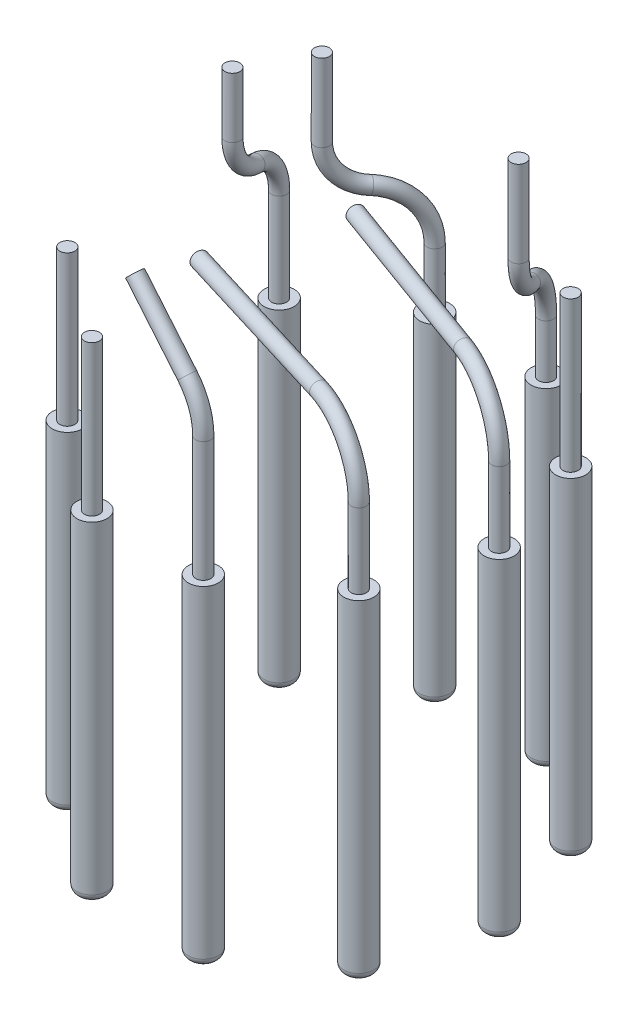
from build123d import *

# Parameters (mm, degrees)
EXTRUDE2_DEPTH        = 4.5
EXTRUDE2_DEPTH_BACK   = 6.5
SKETCH1_R             = 0.5
EXTRUDE2_2_DEPTH      = 4.5
EXTRUDE2_2_DEPTH_BACK = 6.5
EXTRUDE2_3_DEPTH      = 4.5
EXTRUDE2_3_DEPTH_BACK = 6.5
EXTRUDE2_4_DEPTH      = 4.5
EXTRUDE2_4_DEPTH_BACK = 6.5
EXTRUDE2_5_DEPTH      = 4.5
EXTRUDE2_5_DEPTH_BACK = 6.5
EXTRUDE2_6_DEPTH      = 4.5
EXTRUDE2_6_DEPTH_BACK = 6.5
EXTRUDE2_7_DEPTH      = 4.5
EXTRUDE2_7_DEPTH_BACK = 6.5
EXTRUDE2_8_DEPTH      = 4.5
EXTRUDE2_8_DEPTH_BACK = 6.5
EXTRUDE2_9_DEPTH      = 4.5
EXTRUDE2_9_DEPTH_BACK = 6.5
SKETCH3_R             = 0.25
EXTRUDE3_DEPTH        = 5
FILLET1_R             = 0.25
FILLET2_R             = 0.25
FILLET3_R             = 0.25
FILLET4_R             = 0.25
FILLET5_R             = 0.25
FILLET6_R             = 0.25
FILLET7_R             = 0.25
FILLET8_R             = 0.25
FILLET9_R             = 0.25
SKETCH5_R             = 0.25
SKETCH7_R             = 0.25
SKETCH9_R             = 0.25
SKETCH12_R            = 0.25
SKETCH14_R            = 0.25
SKETCH16_R            = 0.25


with BuildPart() as part:
    # Sketch1 → Extrude2 (new, two sides: drawn at the far end of the back side and taken through both)
    with BuildSketch(Plane(origin=(0, 0, 0), x_dir=(1, 0, 0), z_dir=(0, 1, 0)).offset(-EXTRUDE2_DEPTH_BACK)):
        with Locations((6, 0)):
            Circle(SKETCH1_R)
    extrude(amount=EXTRUDE2_DEPTH + EXTRUDE2_DEPTH_BACK)

    # Fillet9
    fillet9_edges = [part.edges().sort_by_distance(p)[0] for p in [
        (5.5, -6.5, 0),
    ]]
    fillet(fillet9_edges, radius=FILLET9_R)

    # Sweep3: sweep along a path in Sketch8
    with BuildLine(Plane(origin=(0.701866671, 0, -1.928362829), x_dir=(0.9396926207859082, 0, 0.3420201433256695), z_dir=(-0.3420201433256695, 0, 0.9396926207859082))) as sweep3_path:
        Line((5.638155725, 4.5), (5.638155725, 7))
        ThreePointArc((5.638155725, 7), (5.052369287, 8.414213562), (3.638155725, 9))
        Line((3.638155725, 9), (-2.361844275, 9))
    # Sketch9 → Sweep3 (sweep)
    with BuildSketch(Plane(origin=(0, 4.5, 0), x_dir=(-1, 0, 0), z_dir=(0, 1, 0))):
        with Locations((-6, 0)):
            Circle(SKETCH9_R)
    sweep(path=sweep3_path.line)


with BuildPart() as body_2:
    # Sketch1 → Extrude2 2 (new, two sides: drawn at the far end of the back side and taken through both)
    with BuildSketch(Plane(origin=(0, 0, 0), x_dir=(1, 0, 0), z_dir=(0, 1, 0)).offset(-EXTRUDE2_2_DEPTH_BACK)):
        with Locations((4.854101966, -3.526711514)):
            Circle(SKETCH1_R)
    extrude(amount=EXTRUDE2_2_DEPTH + EXTRUDE2_2_DEPTH_BACK)

    # Fillet8
    fillet8_edges = [body_2.edges().sort_by_distance(p)[0] for p in [
        (4.354101966, -6.5, 3.526711514),
    ]]
    fillet(fillet8_edges, radius=FILLET8_R)

    # Sweep2: sweep along a path in Sketch6
    with BuildLine(Plane(origin=(-0.571121498, 0, 1.868054247), x_dir=(0.9563047559630353, 0, 0.2923717047227373), z_dir=(-0.2923717047227373, 0, 0.9563047559630353))) as sweep2_path:
        Line((5.673111454, 4.5), (5.673111454, 7))
        ThreePointArc((5.673111454, 7), (5.087325016, 8.414213562), (3.673111454, 9))
        Line((3.673111454, 9), (-2.326888546, 9))
    # Sketch7 → Sweep2 (sweep)
    with BuildSketch(Plane(origin=(0, 4.5, 0), x_dir=(-1, 0, 0), z_dir=(0, 1, 0))):
        with Locations((-4.854101966, 3.526711514)):
            Circle(SKETCH7_R)
    sweep(path=sweep2_path.line)


with BuildPart() as body_3:
    # Sketch1 → Extrude2 3 (new, two sides: drawn at the far end of the back side and taken through both)
    with BuildSketch(Plane(origin=(0, 0, 0), x_dir=(1, 0, 0), z_dir=(0, 1, 0)).offset(-EXTRUDE2_3_DEPTH_BACK)):
        with Locations((1.854101966, -5.706339098)):
            Circle(SKETCH1_R)
    extrude(amount=EXTRUDE2_3_DEPTH + EXTRUDE2_3_DEPTH_BACK)

    # Fillet7
    fillet7_edges = [body_3.edges().sort_by_distance(p)[0] for p in [
        (1.354101966, -6.5, 5.706339098),
    ]]
    fillet(fillet7_edges, radius=FILLET7_R)

    # Sweep1: sweep along a path in Sketch4
    with BuildLine(Plane(origin=(-0.481363705, 0, 5.502012327), x_dir=(0.9961946980917457, 0, 0.08715574274765837), z_dir=(-0.08715574274765837, 0, 0.9961946980917457))) as sweep1_path:
        Line((2.344386771, 4.5), (2.344386771, 8.5))
        ThreePointArc((2.344386771, 8.5), (2.192145836, 9.265366865), (1.758600333, 9.914213562))
        Line((1.758600333, 9.914213562), (-0.155613229, 11.828427125))
    # Sketch5 → Sweep1 (sweep)
    with BuildSketch(Plane(origin=(0, 4.5, 0), x_dir=(-1, 0, 0), z_dir=(0, 1, 0))):
        with Locations((-1.854101966, 5.706339098)):
            Circle(SKETCH5_R)
    sweep(path=sweep1_path.line)


with BuildPart() as body_4:
    # Sketch1 → Extrude2 4 (new, two sides: drawn at the far end of the back side and taken through both)
    with BuildSketch(Plane(origin=(0, 0, 0), x_dir=(1, 0, 0), z_dir=(0, 1, 0)).offset(-EXTRUDE2_4_DEPTH_BACK)):
        with Locations((-1.854101966, -5.706339098)):
            Circle(SKETCH1_R)
    extrude(amount=EXTRUDE2_4_DEPTH + EXTRUDE2_4_DEPTH_BACK)



with BuildPart() as body_5:
    # Sketch1 → Extrude2 5 (new, two sides: drawn at the far end of the back side and taken through both)
    with BuildSketch(Plane(origin=(0, 0, 0), x_dir=(1, 0, 0), z_dir=(0, 1, 0)).offset(-EXTRUDE2_5_DEPTH_BACK)):
        with Locations((-4.854101966, -3.526711514)):
            Circle(SKETCH1_R)
    extrude(amount=EXTRUDE2_5_DEPTH + EXTRUDE2_5_DEPTH_BACK)


with BuildPart() as body_6:
    # Sketch1 → Extrude2 6 (new, two sides: drawn at the far end of the back side and taken through both)
    with BuildSketch(Plane(origin=(0, 0, 0), x_dir=(1, 0, 0), z_dir=(0, 1, 0)).offset(-EXTRUDE2_6_DEPTH_BACK)):
        with Locations((-4.854101966, 3.526711514)):
            Circle(SKETCH1_R)
    extrude(amount=EXTRUDE2_6_DEPTH + EXTRUDE2_6_DEPTH_BACK)

    # Fillet4
    fillet4_edges = [body_6.edges().sort_by_distance(p)[0] for p in [
        (-5.354101966, -6.5, -3.526711514),
    ]]
    fillet(fillet4_edges, radius=FILLET4_R)

    # Sweep6: sweep along a path in Sketch15
    with BuildLine(Plane(origin=(-3.647260912, 0, 0.977280616), x_dir=(0.258819045102518, 0, 0.9659258262890691), z_dir=(-0.9659258262890691, 0, 0.258819045102518))) as sweep6_path:
        Line((-4.662875769, 4.5), (-4.662875769, 7.608633541))
        ThreePointArc((-4.662875769, 7.608633541), (-4.356609407, 8.516928647), (-3.562875769, 9.054316771))
        ThreePointArc((-3.562875769, 9.054316771), (-2.76914213, 9.591704894), (-2.462875769, 10.5))
        Line((-2.462875769, 10.5), (-2.462875769, 12.5))
    # Sketch16 → Sweep6 (sweep)
    with BuildSketch(Plane(origin=(0, 4.5, 0), x_dir=(1, 0, 0), z_dir=(0, 1, 0))):
        with Locations((-4.854101966, 3.526711514)):
            Circle(SKETCH16_R)
    sweep(path=sweep6_path.line)


with BuildPart() as body_7:
    # Sketch1 → Extrude2 7 (new, two sides: drawn at the far end of the back side and taken through both)
    with BuildSketch(Plane(origin=(0, 0, 0), x_dir=(1, 0, 0), z_dir=(0, 1, 0)).offset(-EXTRUDE2_7_DEPTH_BACK)):
        with Locations((-1.854101966, 5.706339098)):
            Circle(SKETCH1_R)
    extrude(amount=EXTRUDE2_7_DEPTH + EXTRUDE2_7_DEPTH_BACK)

    # Fillet3
    fillet3_edges = [body_7.edges().sort_by_distance(p)[0] for p in [
        (-2.354101966, -6.5, -5.706339098),
    ]]
    fillet(fillet3_edges, radius=FILLET3_R)

    # Sweep5: sweep along a path in Sketch13
    with BuildLine(Plane(origin=(-3.861493785, 0, -2.229434476), x_dir=(0.5000000000000009, 0, -0.866025403784438), z_dir=(0.8660254037844382, 0, 0.500000000000001))) as sweep5_path:
        Line((4.014783638, 4.5), (4.014783638, 6.5))
        ThreePointArc((4.014783638, 6.5), (3.573171083, 7.753566341), (2.443355067, 8.453542047))
        ThreePointArc((2.443355067, 8.453542047), (1.595993054, 8.978523827), (1.264783638, 9.918698583))
        Line((1.264783638, 9.918698583), (1.264783638, 12.5))
    # Sketch14 → Sweep5 (sweep)
    with BuildSketch(Plane(origin=(0, 4.5, 0), x_dir=(1, 0, 0), z_dir=(0, 1, 0))):
        with Locations((-1.854101966, 5.706339098)):
            Circle(SKETCH14_R)
    sweep(path=sweep5_path.line)


with BuildPart() as body_8:
    # Sketch1 → Extrude2 8 (new, two sides: drawn at the far end of the back side and taken through both)
    with BuildSketch(Plane(origin=(0, 0, 0), x_dir=(1, 0, 0), z_dir=(0, 1, 0)).offset(-EXTRUDE2_8_DEPTH_BACK)):
        with Locations((1.854101966, 5.706339098)):
            Circle(SKETCH1_R)
    extrude(amount=EXTRUDE2_8_DEPTH + EXTRUDE2_8_DEPTH_BACK)

    # Fillet2
    fillet2_edges = [body_8.edges().sort_by_distance(p)[0] for p in [
        (1.354101966, -6.5, -5.706339098),
    ]]
    fillet(fillet2_edges, radius=FILLET2_R)

    # Sweep4: sweep along a path in Sketch10
    with BuildLine(Plane(origin=(3.861493785, 0, -2.229434476), x_dir=(-0.500000000000001, 0, -0.8660254037844382), z_dir=(0.8660254037844382, 0, -0.500000000000001))) as sweep4_path:
        Line((4.014783638, 4.5), (4.014783638, 6.275624505))
        ThreePointArc((4.014783638, 6.275624505), (3.61835109, 7.470853114), (2.58621221, 8.1922542))
        ThreePointArc((2.58621221, 8.1922542), (1.81210805, 8.733305014), (1.514783638, 9.629726471))
        Line((1.514783638, 9.629726471), (1.514783638, 12.5))
    # Sketch12 → Sweep4 (sweep)
    with BuildSketch(Plane(origin=(0, 4.5, 0), x_dir=(1, 0, 0), z_dir=(0, 1, 0))):
        with Locations((1.854101966, 5.706339098)):
            Circle(SKETCH12_R)
    sweep(path=sweep4_path.line)


with BuildPart() as body_9:
    # Sketch1 → Extrude2 9 (new, two sides: drawn at the far end of the back side and taken through both)
    with BuildSketch(Plane(origin=(0, 0, 0), x_dir=(1, 0, 0), z_dir=(0, 1, 0)).offset(-EXTRUDE2_9_DEPTH_BACK)):
        with Locations((4.854101966, 3.526711514)):
            Circle(SKETCH1_R)
    extrude(amount=EXTRUDE2_9_DEPTH + EXTRUDE2_9_DEPTH_BACK)


with BuildPart() as body_4_1:
    add(body_4.part)

    add(body_5.part)  # Extrude3 merges body 5

    add(body_9.part)  # Extrude3 merges body 9
    # Sketch3 → Extrude3 (add)
    with BuildSketch(Plane(origin=(0, 4.5, 0), x_dir=(-1, 0, 0), z_dir=(0, 1, 0))):
        with Locations((4.854101966, 3.526711514)):
            Circle(SKETCH3_R)
        with Locations((1.854101966, 5.706339098)):
            Circle(SKETCH3_R)
        with Locations((-4.854101966, -3.526711514)):
            Circle(SKETCH3_R)
    extrude(amount=EXTRUDE3_DEPTH)

    # Fillet1
    fillet1_edges = [body_4_1.edges().sort_by_distance(p)[0] for p in [
        (4.354101966, -6.5, -3.526711514),
    ]]
    fillet(fillet1_edges, radius=FILLET1_R)

    # Fillet5
    fillet5_edges = [body_4_1.edges().sort_by_distance(p)[0] for p in [
        (-5.354101966, -6.5, 3.526711514),
    ]]
    fillet(fillet5_edges, radius=FILLET5_R)

    # Fillet6
    fillet6_edges = [body_4_1.edges().sort_by_distance(p)[0] for p in [
        (-2.354101966, -6.5, 5.706339098),
    ]]
    fillet(fillet6_edges, radius=FILLET6_R)


solid = Compound([part.part, body_2.part, body_3.part, body_6.part, body_7.part, body_8.part, body_4_1.part])
